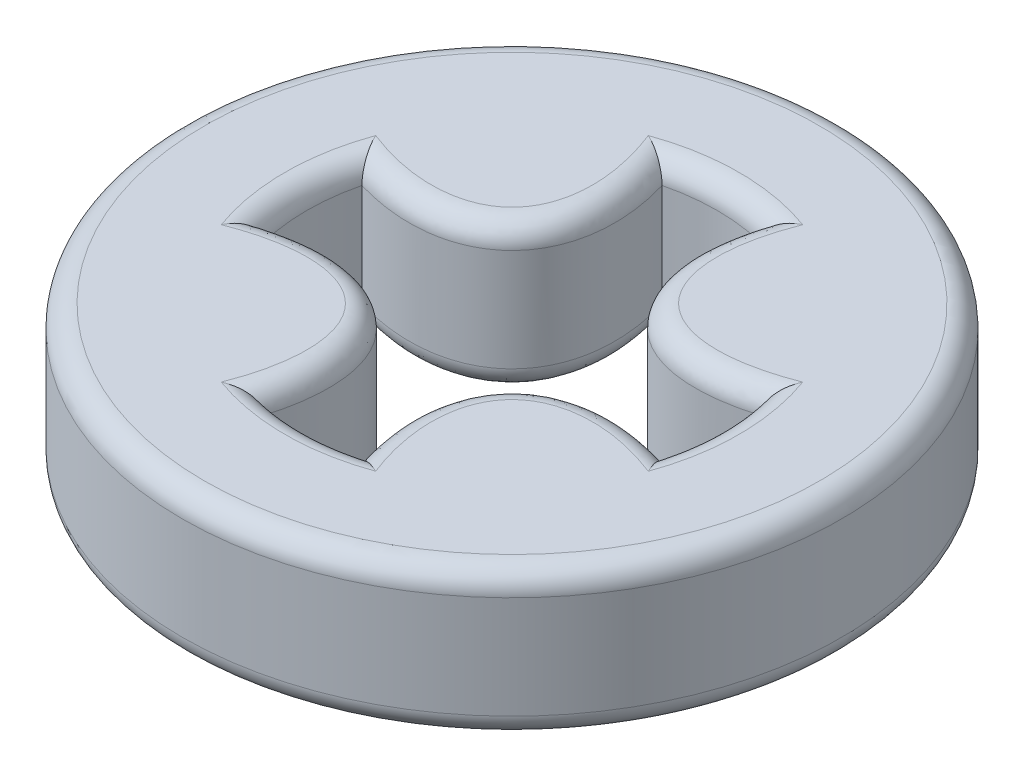
from build123d import *

# Parameters (mm, degrees)
SKETCH4_R           = 4.5
BOSS_EXTRUDE3_DEPTH = 2
CUT_EXTRUDE2_DEPTH  = 2
FILLET1_R           = 0.3


with BuildPart() as part:
    # Sketch4 → Boss-Extrude3 (new body)
    with BuildSketch(Plane(origin=(0, 0, 0), x_dir=(1, 0, 0), z_dir=(0, 1, 0))):
        Circle(SKETCH4_R)
    extrude(amount=BOSS_EXTRUDE3_DEPTH)

    # Sketch3 → Cut-Extrude2 (cut)
    with BuildSketch(Plane(origin=(0, 0, 0), x_dir=(1, 0, 0), z_dir=(0, 1, 0))):
        with BuildLine():
            ThreePointArc((-2.718783674, 0.669488859), (-2.8, 0), (-2.718783674, -0.669488859))
            add(Edge.make_bspline(
                [(-0.669488859, -2.718783674), (0.190922811, 0.190922811), (-2.718783674, -0.669488859)],
                knots=[2.331232968, 2.331232968, 2.331232968, 3.951952339, 3.951952339, 3.951952339], degree=2, weights=[1, 0.689237872, 1]))
            ThreePointArc((-0.669488859, -2.718783674), (0, -2.8), (0.669488859, -2.718783674))
            add(Edge.make_bspline(
                [(2.718783674, -0.669488859), (-0.190922811, 0.190922811), (0.669488859, -2.718783674)],
                knots=[2.331232968, 2.331232968, 2.331232968, 3.951952339, 3.951952339, 3.951952339], degree=2, weights=[1, 0.689237872, 1]))
            ThreePointArc((2.718783674, -0.669488859), (2.8, 0), (2.718783674, 0.669488859))
            add(Edge.make_bspline(
                [(0.669488859, 2.718783674), (-0.190922811, -0.190922811), (2.718783674, 0.669488859)],
                knots=[2.331232968, 2.331232968, 2.331232968, 3.951952339, 3.951952339, 3.951952339], degree=2, weights=[1, 0.689237872, 1]))
            ThreePointArc((0.669488859, 2.718783674), (0, 2.8), (-0.669488859, 2.718783674))
            add(Edge.make_bspline(
                [(-2.718783674, 0.669488859), (0.190922811, -0.190922811), (-0.669488859, 2.718783674)],
                knots=[2.331232968, 2.331232968, 2.331232968, 3.951952339, 3.951952339, 3.951952339], degree=2, weights=[1, 0.689237872, 1]))
        make_face()
    extrude(amount=CUT_EXTRUDE2_DEPTH, mode=Mode.SUBTRACT)

    # Fillet1
    fillet1_edges = [part.edges().sort_by_distance(p)[0] for p in [
        (0.924866705, 0, -0.92513332),
        (0, 0, -2.8),
        (-0.92513332, 0, -0.924866705),
        (-2.8, 0, 0),
        (-0.924866705, 0, 0.92513332),
        (0, 0, 2.8),
        (0.92513332, 0, 0.924866705),
        (2.8, 0, 0),
        (0.924866705, 2, -0.92513332),
        (0, 2, -2.8),
        (-0.92513332, 2, -0.924866705),
        (-2.8, 2, 0),
        (-0.924866705, 2, 0.92513332),
        (0, 2, 2.8),
        (0.92513332, 2, 0.924866705),
        (2.8, 2, 0),
        (-4.5, 0, 0),
        (-4.5, 2, 0),
    ]]
    fillet(fillet1_edges, radius=FILLET1_R)


solid = part.part
